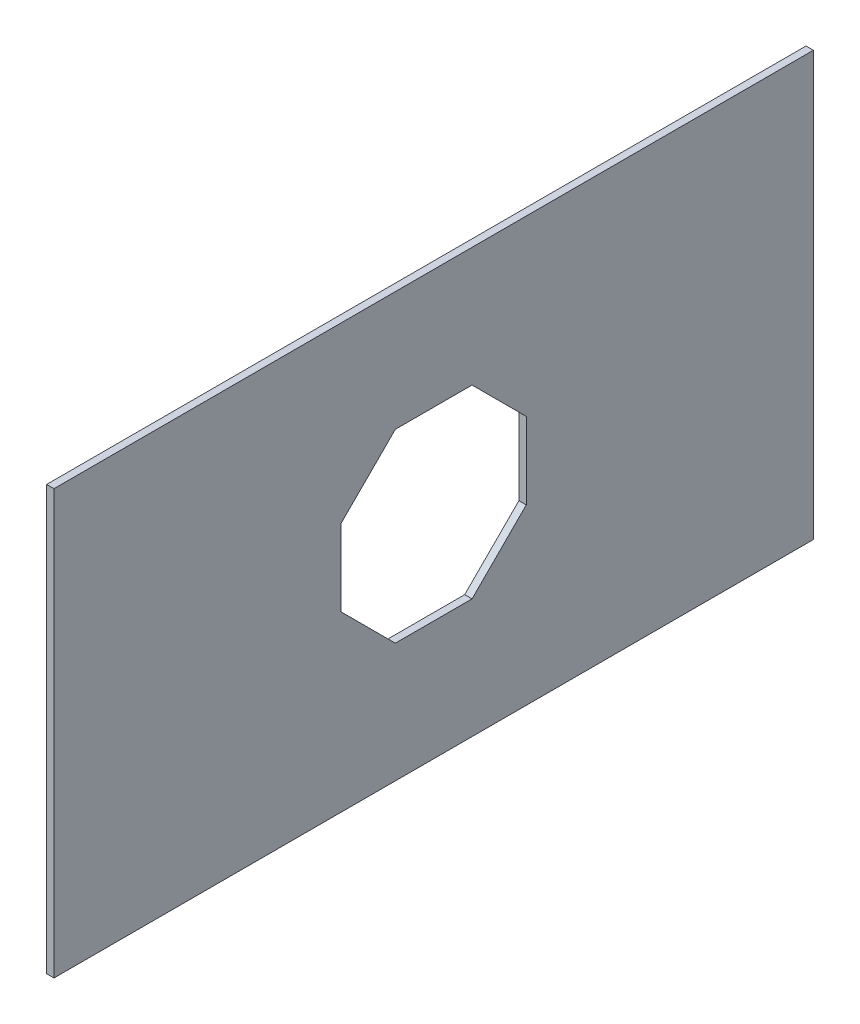
from build123d import *

# Parameters (mm, degrees)
SKETCH1_W           = 492.125
SKETCH1_H           = 274.6375
BOSS_EXTRUDE1_DEPTH = 4.7625
CUT_EXTRUDE1_REACH  = 6.763


with BuildPart() as part:
    # Sketch1 → Boss-Extrude1 (new body)
    with BuildSketch(Plane(origin=(0, 0, 0), x_dir=(0, 0, -1), z_dir=(1, 0, 0))):
        Rectangle(SKETCH1_W, SKETCH1_H)
    extrude(amount=BOSS_EXTRUDE1_DEPTH)

    # Sketch2 → Cut-Extrude1 (cut, up to next)
    with BuildSketch(Plane(origin=(4.7625, 0, 0), x_dir=(0, 0, -1), z_dir=(1, 0, 0)), mode=Mode.PRIVATE) as cut_extrude1_sk1:
        Polygon((-24.852813742, -60), (24.852813742, -60), (42.426406871, -42.426406871), (60, -24.852813742), (60, 24.852813742), (24.852813742, 60), (-24.852813742, 60), (-60, 24.852813742), (-60, -24.852813742), align=None)
    cut_extrude1_tool1 = extrude(cut_extrude1_sk1.sketch, amount=-CUT_EXTRUDE1_REACH, mode=Mode.PRIVATE) & part.part
    add(cut_extrude1_tool1.solids().sort_by_distance((4.7625, 0, 0))[0], mode=Mode.SUBTRACT)


solid = part.part
